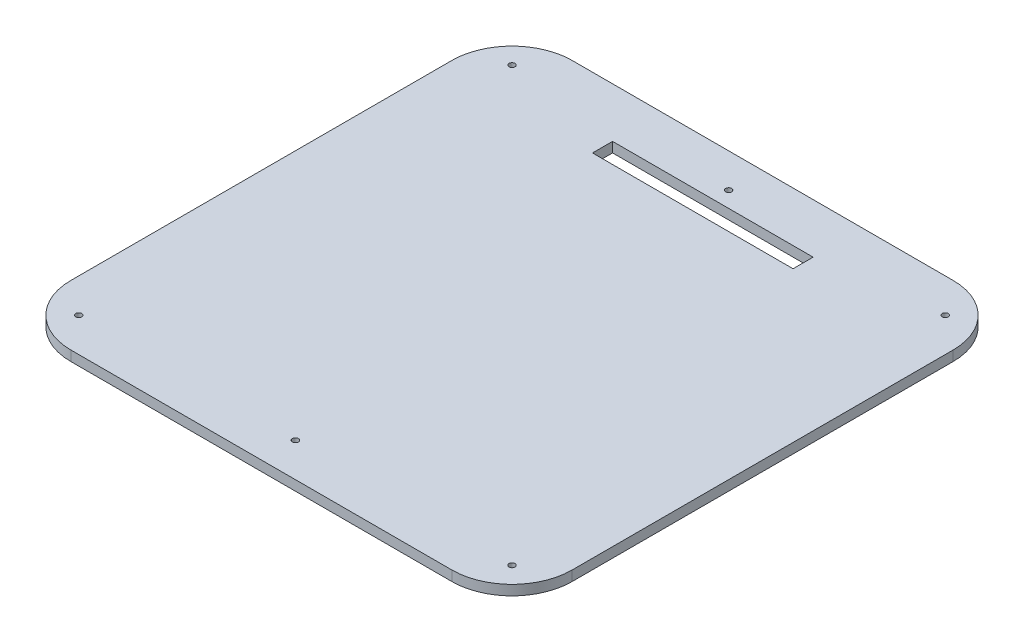
from build123d import *

# Parameters (mm, degrees)
SKETCH1_W           = 250
SKETCH1_H           = 250
BOSS_EXTRUDE1_DEPTH = 2.5
CUT_EXTRUDE1_REACH  = 7
SKETCH2_W           = 100
SKETCH2_H           = 10
CUT_EXTRUDE2_REACH  = 7
SKETCH4_R           = 1.5
FILLET1_R           = 30


with BuildPart() as part:
    # Sketch1 → Boss-Extrude1 (new body, symmetric)
    with BuildSketch(Plane(origin=(0, 0, 0), x_dir=(1, 0, 0), z_dir=(0, 1, 0))):
        Rectangle(SKETCH1_W, SKETCH1_H)
    extrude(amount=BOSS_EXTRUDE1_DEPTH, both=True)

    # Sketch2 → Cut-Extrude1 (cut, up to next)
    with BuildSketch(Plane(origin=(0, 2.5, 0), x_dir=(1, 0, 0), z_dir=(0, 1, 0)), mode=Mode.PRIVATE) as cut_extrude1_sk1:
        with Locations((0, 95.139170266)):
            Rectangle(SKETCH2_W, SKETCH2_H)
    cut_extrude1_tool1 = extrude(cut_extrude1_sk1.sketch, amount=-CUT_EXTRUDE1_REACH, mode=Mode.PRIVATE) & part.part
    add(cut_extrude1_tool1.solids().sort_by_distance((0, 2.5, -95.13917))[0], mode=Mode.SUBTRACT)

    # Sketch4 → Cut-Extrude2 (cut, up to next)
    with BuildSketch(Plane(origin=(0, 2.5, 0), x_dir=(1, 0, 0), z_dir=(0, 1, 0)), mode=Mode.PRIVATE) as cut_extrude2_sk1:
        with Locations((-108, 108)):
            Circle(SKETCH4_R)
    cut_extrude2_tool1 = extrude(cut_extrude2_sk1.sketch, amount=-CUT_EXTRUDE2_REACH, mode=Mode.PRIVATE) & part.part
    add(cut_extrude2_tool1.solids().sort_by_distance((-108, 2.5, -108))[0], mode=Mode.SUBTRACT)
    # Sketch4 → Cut-Extrude2 (cut, up to next)
    with BuildSketch(Plane(origin=(0, 2.5, 0), x_dir=(1, 0, 0), z_dir=(0, 1, 0)), mode=Mode.PRIVATE) as cut_extrude2_sk2:
        with Locations((0, 108)):
            Circle(SKETCH4_R)
    cut_extrude2_tool2 = extrude(cut_extrude2_sk2.sketch, amount=-CUT_EXTRUDE2_REACH, mode=Mode.PRIVATE) & part.part
    add(cut_extrude2_tool2.solids().sort_by_distance((0, 2.5, -108))[0], mode=Mode.SUBTRACT)
    # Sketch4 → Cut-Extrude2 (cut, up to next)
    with BuildSketch(Plane(origin=(0, 2.5, 0), x_dir=(1, 0, 0), z_dir=(0, 1, 0)), mode=Mode.PRIVATE) as cut_extrude2_sk3:
        with Locations((108, 108)):
            Circle(SKETCH4_R)
    cut_extrude2_tool3 = extrude(cut_extrude2_sk3.sketch, amount=-CUT_EXTRUDE2_REACH, mode=Mode.PRIVATE) & part.part
    add(cut_extrude2_tool3.solids().sort_by_distance((108, 2.5, -108))[0], mode=Mode.SUBTRACT)
    # Sketch4 → Cut-Extrude2 (cut, up to next)
    with BuildSketch(Plane(origin=(0, 2.5, 0), x_dir=(1, 0, 0), z_dir=(0, 1, 0)), mode=Mode.PRIVATE) as cut_extrude2_sk4:
        with Locations((108, -108)):
            Circle(SKETCH4_R)
    cut_extrude2_tool4 = extrude(cut_extrude2_sk4.sketch, amount=-CUT_EXTRUDE2_REACH, mode=Mode.PRIVATE) & part.part
    add(cut_extrude2_tool4.solids().sort_by_distance((108, 2.5, 108))[0], mode=Mode.SUBTRACT)
    # Sketch4 → Cut-Extrude2 (cut, up to next)
    with BuildSketch(Plane(origin=(0, 2.5, 0), x_dir=(1, 0, 0), z_dir=(0, 1, 0)), mode=Mode.PRIVATE) as cut_extrude2_sk5:
        with Locations((0, -108)):
            Circle(SKETCH4_R)
    cut_extrude2_tool5 = extrude(cut_extrude2_sk5.sketch, amount=-CUT_EXTRUDE2_REACH, mode=Mode.PRIVATE) & part.part
    add(cut_extrude2_tool5.solids().sort_by_distance((0, 2.5, 108))[0], mode=Mode.SUBTRACT)
    # Sketch4 → Cut-Extrude2 (cut, up to next)
    with BuildSketch(Plane(origin=(0, 2.5, 0), x_dir=(1, 0, 0), z_dir=(0, 1, 0)), mode=Mode.PRIVATE) as cut_extrude2_sk6:
        with Locations((-108, -108)):
            Circle(SKETCH4_R)
    cut_extrude2_tool6 = extrude(cut_extrude2_sk6.sketch, amount=-CUT_EXTRUDE2_REACH, mode=Mode.PRIVATE) & part.part
    add(cut_extrude2_tool6.solids().sort_by_distance((-108, 2.5, 108))[0], mode=Mode.SUBTRACT)

    # Fillet1
    fillet1_edges = [part.edges().sort_by_distance(p)[0] for p in [
        (125, 0, 125),
        (-125, 0, 125),
        (-125, 0, -125),
        (125, 0, -125),
    ]]
    fillet(fillet1_edges, radius=FILLET1_R)


solid = part.part
